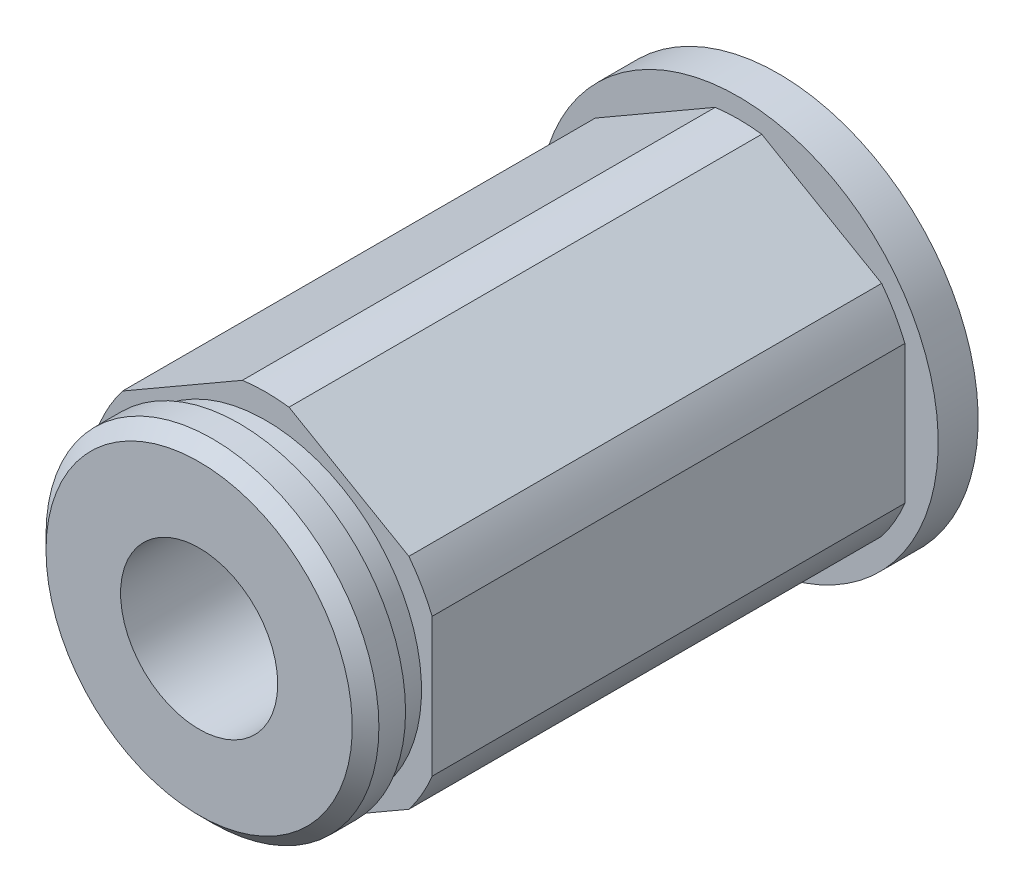
from build123d import *

# Parameters (mm, degrees)
SKETCH1_R               = 6.35
BASIC_ROD_DEPTH         = 9.779
BASIC_ROD_DEPTH_BACK    = 9.779
THEX_DEPTH              = 9.779
SKETCH2_R               = 2.9972
INTERNAL_CUT_DEPTH      = 13.319
INTERNAL_CUT_DEPTH_BACK = 10.779
SKETCH9_R               = 7.62
SKETCH9_R_2             = 2.9972
BOSS_EXTRUDE1_DEPTH     = 1.524


with BuildPart() as part:
    # Sketch1 → Basic Rod (new body, two sides)
    with BuildSketch(Plane.XY) as basic_rod_sk:
        Circle(SKETCH1_R)
    extrude(amount=BASIC_ROD_DEPTH)
    extrude(basic_rod_sk.sketch, amount=-BASIC_ROD_DEPTH_BACK)

    # Sketch8 → THex (add, symmetric)
    with BuildSketch(Plane.XY):
        with BuildLine():
            Line((-0.888411378, 6.819423871), (-5.461588622, 4.179098758))
            ThreePointArc((-5.461588622, 4.179098758), (-5.955700003, 3.438525), (-6.35, 2.640325113))
            Line((-6.35, 2.640325113), (-6.35, -2.640325113))
            ThreePointArc((-6.35, -2.640325113), (-5.955700003, -3.438525), (-5.461588622, -4.179098758))
            Line((-5.461588622, -4.179098758), (-0.888411378, -6.819423871))
            ThreePointArc((-0.888411378, -6.819423871), (0, -6.87705), (0.888411378, -6.819423871))
            Line((0.888411378, -6.819423871), (5.461588622, -4.179098758))
            ThreePointArc((5.461588622, -4.179098758), (5.955700003, -3.438525), (6.35, -2.640325113))
            Line((6.35, -2.640325113), (6.35, 2.640325113))
            ThreePointArc((6.35, 2.640325113), (5.955700003, 3.438525), (5.461588622, 4.179098758))
            Line((5.461588622, 4.179098758), (0.888411378, 6.819423871))
            ThreePointArc((0.888411378, 6.819423871), (0, 6.87705), (-0.888411378, 6.819423871))
        make_face()
    extrude(amount=THEX_DEPTH, both=True)

    # Sketch7 → 1stSnapRing (revolve)
    with BuildSketch(Plane(origin=(0, 0, 0), x_dir=(0, 0, -1), z_dir=(1, 0, 0))):
        Polygon((-9.779, 5.9436), (-10.795, 5.9436), (-10.795, 6.35), (-11.811, 6.35), (-12.319, 5.842), (-12.319, 0), (-9.779, 0), align=None)
    revolve(axis=Axis((0, 0, -38.2778), (0, 0, 1)))

    # Sketch2 → Internal Cut (cut, two sides)
    with BuildSketch(Plane.XY) as internal_cut_sk:
        Circle(SKETCH2_R)
    extrude(amount=INTERNAL_CUT_DEPTH, mode=Mode.SUBTRACT)
    extrude(internal_cut_sk.sketch, amount=-INTERNAL_CUT_DEPTH_BACK, mode=Mode.SUBTRACT)

    # Sketch9 → Boss-Extrude1 (add)
    with BuildSketch(Plane(origin=(0, 0, -9.779), x_dir=(-1, 0, 0), z_dir=(0, 0, -1))):
        Circle(SKETCH9_R)
        Circle(SKETCH9_R_2, mode=Mode.SUBTRACT)
    extrude(amount=-BOSS_EXTRUDE1_DEPTH)


solid = part.part
